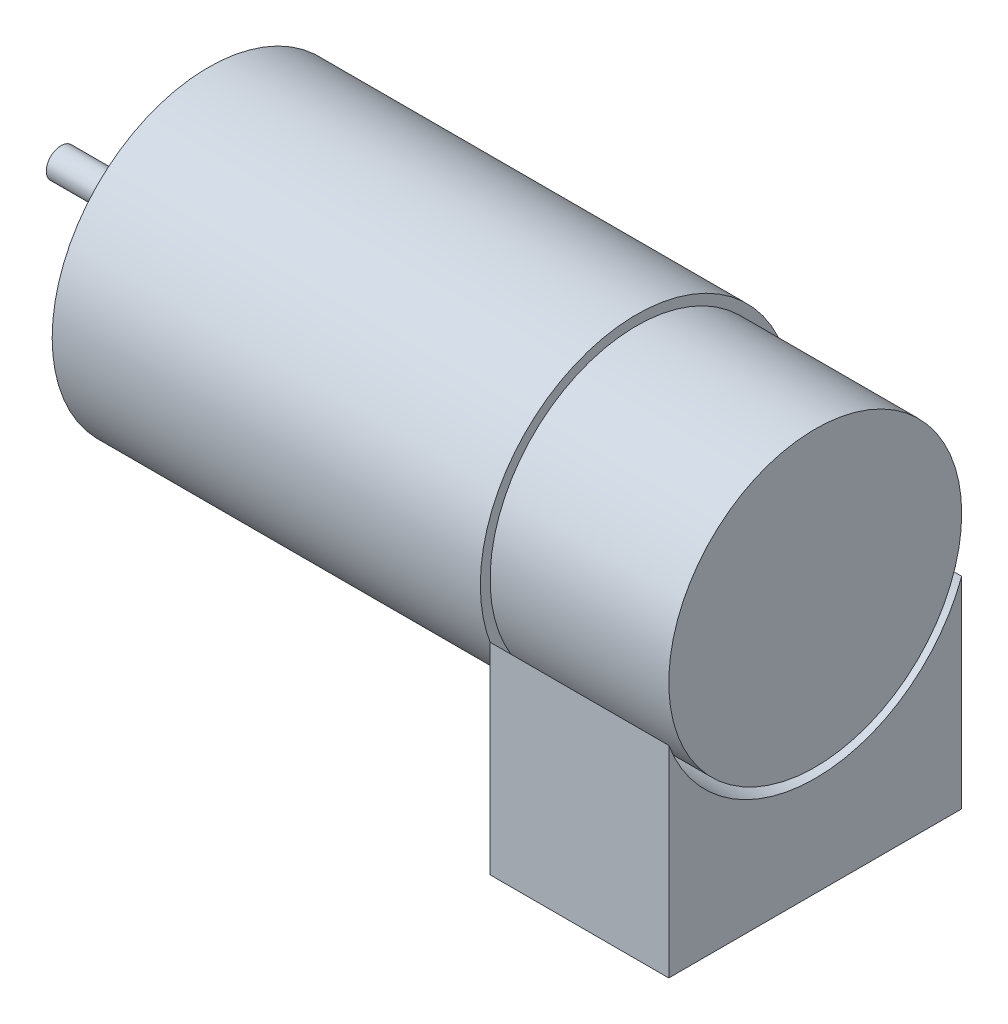
from build123d import *

# Parameters (mm, degrees)
SKETCH1_W                   = 13
SKETCH1_H                   = 1.5
BOSS_EXTRUDE1_DEPTH         = 18.3
TAP_DRILL_FOR_M2_TAP1_D     = 1.6
TAP_DRILL_FOR_M2_TAP1_DEPTH = 3.119311505
TAP_DRILL_FOR_M2_TAP1_TIP   = 0.480688495


with BuildPart() as part:
    # Sketch1 → Revolve3 (revolve)
    with BuildSketch(Plane(origin=(0, 0, 0), x_dir=(1, 0, 0), z_dir=(0, 1, 0))):
        with Locations((6.5, 0.75)):
            Rectangle(SKETCH1_W, SKETCH1_H)
        Polygon((13, 1.5), (13, 0), (15.1, 0), (15.1, 5), (13, 5), align=None)
        Polygon((15.1, 5), (15.1, 0), (58.95, 0), (58.95, 16), (15.1, 16), align=None)
    revolve(axis=Axis((0, 0, 0), (1, 0, 0)))

    # Sketch2 → Boss-Extrude1 (add)
    with BuildSketch(Plane(origin=(58.95, 0, 0), x_dir=(0, 0, -1), z_dir=(1, 0, 0))):
        with BuildLine():
            ThreePointArc((15, -5.567764363), (0, -16), (-15, -5.567764363))
            Line((-15, -5.567764363), (-15, -26.2))
            Line((-15, -26.2), (15, -26.2))
            Line((15, -26.2), (15, -5.567764363))
        make_face()
        with BuildLine():
            Line((15, 0), (0, 0))
            Line((0, 0), (-15, 0))
            ThreePointArc((-15, 0), (0, -15), (15, 0))
        make_face()
        with BuildLine():
            Line((-15, 0), (0, 0))
            Line((0, 0), (15, 0))
            ThreePointArc((15, 0), (0, 15), (-15, 0))
        make_face()
    extrude(amount=BOSS_EXTRUDE1_DEPTH)

    # Tap Drill for M2 Tap1
    with Locations(Plane(origin=(15.1, 8.5, 0), x_dir=(0, 0, -1), z_dir=(-1, 0, 0))):
        with Locations((0, 0), (7.339624938, 12.787179232), (-7.361215932, 12.75), (-0.054633803, 16.999824419)):
            Hole(TAP_DRILL_FOR_M2_TAP1_D / 2, depth=TAP_DRILL_FOR_M2_TAP1_DEPTH)
            with Locations((0, 0, -(TAP_DRILL_FOR_M2_TAP1_DEPTH + TAP_DRILL_FOR_M2_TAP1_TIP / 2))):  # 118° drill point
                Cone(0, TAP_DRILL_FOR_M2_TAP1_D / 2, TAP_DRILL_FOR_M2_TAP1_TIP, mode=Mode.SUBTRACT)


solid = part.part
